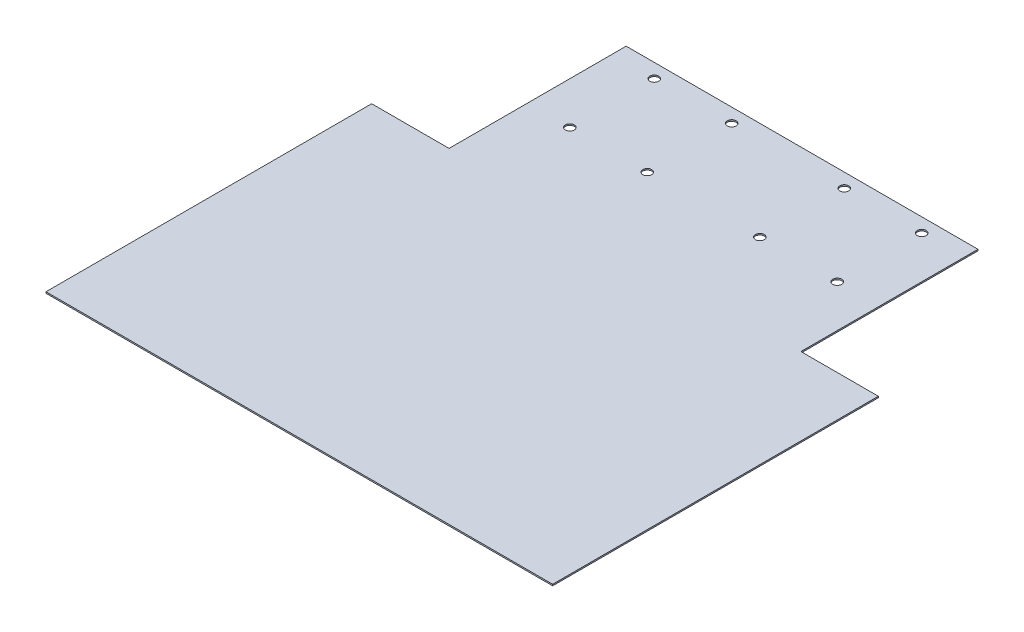
from build123d import *

# Parameters (mm, degrees)
SALIENTE_EXTRUIR1_DEPTH = 0.5
CORTAR_EXTRUIR1_REACH   = 182
CROQUIS5_R              = 1.585
CORTAR_EXTRUIR3_DEPTH   = 0.5
CORTAR_EXTRUIR4_REACH   = 2.5
CROQUIS6_R              = 1.585
CORTAR_EXTRUIR5_REACH   = 2.5
CROQUIS7_R              = 1.585
CROQUIS8_R              = 1.585
CORTAR_EXTRUIR6_DEPTH   = 0.5


with BuildPart() as part:
    # Croquis2 → Saliente-Extruir1 (new body)
    with BuildSketch(Plane(origin=(0, 0, 0), x_dir=(1, 0, 0), z_dir=(0, 1, 0))):
        Polygon((-90, 26.39), (-62.5, 26.39), (-62.5, 89.31), (62.5, 89.31), (62.5, 26.39), (90, 26.39), (90, -89.31), (-90, -89.31), align=None)
    saliente_extruir1 = extrude(amount=SALIENTE_EXTRUIR1_DEPTH)

    # Croquis3 → Cortar-Extruir1 (cut, up to next)
    with BuildSketch(Plane(origin=(90, 0, 0), x_dir=(0, 0, -1), z_dir=(1, 0, 0)), mode=Mode.PRIVATE) as cortar_extruir1_sk1:
        Polygon((-89.31, 0), (-87.93626129, 0.5), (-89.31, 0.5), align=None)
    cortar_extruir1_tool1 = extrude(cortar_extruir1_sk1.sketch, amount=-CORTAR_EXTRUIR1_REACH, mode=Mode.PRIVATE) & part.part
    add(cortar_extruir1_tool1.solids().sort_by_distance((90, 0.333333, 88.852087))[0], mode=Mode.SUBTRACT)

    # Croquis5 → Cortar-Extruir3 (cut)
    with BuildSketch(Plane(origin=(0, 0.5, 0), x_dir=(1, 0, 0), z_dir=(0, 1, 0))):
        with Locations((74, -24.974980583)):
            Circle(CROQUIS5_R)
    cortar_extruir3 = extrude(amount=-CORTAR_EXTRUIR3_DEPTH, mode=Mode.SUBTRACT)

    # Simetría1: Cortar-Extruir3 across plane
    add(cortar_extruir3.mirror(Plane(origin=(0, 0, 0), x_dir=(0, 0, 1), z_dir=(1, 0, 0))), mode=Mode.SUBTRACT)

    # Croquis6 → Cortar-Extruir4 (cut, up to next)
    with BuildSketch(Plane(origin=(0, 0.5, 0), x_dir=(1, 0, 0), z_dir=(0, 1, 0)), mode=Mode.PRIVATE) as cortar_extruir4_sk1:
        with Locations((-56.5, 35.81)):
            Circle(CROQUIS6_R)
    cortar_extruir4_tool1 = extrude(cortar_extruir4_sk1.sketch, amount=-CORTAR_EXTRUIR4_REACH, mode=Mode.PRIVATE) & part.part
    add(cortar_extruir4_tool1.solids().sort_by_distance((-56.5, 0.5, -35.81))[0], mode=Mode.SUBTRACT)
    # Croquis6 → Cortar-Extruir4 (cut, up to next)
    with BuildSketch(Plane(origin=(0, 0.5, 0), x_dir=(1, 0, 0), z_dir=(0, 1, 0)), mode=Mode.PRIVATE) as cortar_extruir4_sk2:
        with Locations((-15.5, 35.81)):
            Circle(CROQUIS6_R)
    cortar_extruir4_tool2 = extrude(cortar_extruir4_sk2.sketch, amount=-CORTAR_EXTRUIR4_REACH, mode=Mode.PRIVATE) & part.part
    add(cortar_extruir4_tool2.solids().sort_by_distance((-15.5, 0.5, -35.81))[0], mode=Mode.SUBTRACT)
    # Croquis6 → Cortar-Extruir4 (cut, up to next)
    with BuildSketch(Plane(origin=(0, 0.5, 0), x_dir=(1, 0, 0), z_dir=(0, 1, 0)), mode=Mode.PRIVATE) as cortar_extruir4_sk3:
        with Locations((-15.5, 84.31)):
            Circle(CROQUIS6_R)
    cortar_extruir4_tool3 = extrude(cortar_extruir4_sk3.sketch, amount=-CORTAR_EXTRUIR4_REACH, mode=Mode.PRIVATE) & part.part
    add(cortar_extruir4_tool3.solids().sort_by_distance((-15.5, 0.5, -84.31))[0], mode=Mode.SUBTRACT)
    # Croquis6 → Cortar-Extruir4 (cut, up to next)
    with BuildSketch(Plane(origin=(0, 0.5, 0), x_dir=(1, 0, 0), z_dir=(0, 1, 0)), mode=Mode.PRIVATE) as cortar_extruir4_sk4:
        with Locations((-56.5, 84.31)):
            Circle(CROQUIS6_R)
    cortar_extruir4_tool4 = extrude(cortar_extruir4_sk4.sketch, amount=-CORTAR_EXTRUIR4_REACH, mode=Mode.PRIVATE) & part.part
    add(cortar_extruir4_tool4.solids().sort_by_distance((-56.5, 0.5, -84.31))[0], mode=Mode.SUBTRACT)

    # Croquis7 → Cortar-Extruir5 (cut, up to next)
    with BuildSketch(Plane(origin=(0, 0.5, 0), x_dir=(1, 0, 0), z_dir=(0, 1, 0)), mode=Mode.PRIVATE) as cortar_extruir5_sk1:
        with Locations((56.5, 35.81)):
            Circle(CROQUIS7_R)
    cortar_extruir5_tool1 = extrude(cortar_extruir5_sk1.sketch, amount=-CORTAR_EXTRUIR5_REACH, mode=Mode.PRIVATE) & part.part
    add(cortar_extruir5_tool1.solids().sort_by_distance((56.5, 0.5, -35.81))[0], mode=Mode.SUBTRACT)
    # Croquis7 → Cortar-Extruir5 (cut, up to next)
    with BuildSketch(Plane(origin=(0, 0.5, 0), x_dir=(1, 0, 0), z_dir=(0, 1, 0)), mode=Mode.PRIVATE) as cortar_extruir5_sk2:
        with Locations((15.5, 35.81)):
            Circle(CROQUIS7_R)
    cortar_extruir5_tool2 = extrude(cortar_extruir5_sk2.sketch, amount=-CORTAR_EXTRUIR5_REACH, mode=Mode.PRIVATE) & part.part
    add(cortar_extruir5_tool2.solids().sort_by_distance((15.5, 0.5, -35.81))[0], mode=Mode.SUBTRACT)
    # Croquis7 → Cortar-Extruir5 (cut, up to next)
    with BuildSketch(Plane(origin=(0, 0.5, 0), x_dir=(1, 0, 0), z_dir=(0, 1, 0)), mode=Mode.PRIVATE) as cortar_extruir5_sk3:
        with Locations((15.5, 84.31)):
            Circle(CROQUIS7_R)
    cortar_extruir5_tool3 = extrude(cortar_extruir5_sk3.sketch, amount=-CORTAR_EXTRUIR5_REACH, mode=Mode.PRIVATE) & part.part
    add(cortar_extruir5_tool3.solids().sort_by_distance((15.5, 0.5, -84.31))[0], mode=Mode.SUBTRACT)
    # Croquis7 → Cortar-Extruir5 (cut, up to next)
    with BuildSketch(Plane(origin=(0, 0.5, 0), x_dir=(1, 0, 0), z_dir=(0, 1, 0)), mode=Mode.PRIVATE) as cortar_extruir5_sk4:
        with Locations((56.5, 84.31)):
            Circle(CROQUIS7_R)
    cortar_extruir5_tool4 = extrude(cortar_extruir5_sk4.sketch, amount=-CORTAR_EXTRUIR5_REACH, mode=Mode.PRIVATE) & part.part
    add(cortar_extruir5_tool4.solids().sort_by_distance((56.5, 0.5, -84.31))[0], mode=Mode.SUBTRACT)

    # Simetría3: Saliente-Extruir1 across plane
    add(saliente_extruir1.mirror(Plane(origin=(0, 0, 0), x_dir=(0, 0, 1), z_dir=(1, 0, 0))))

    # Croquis8 → Cortar-Extruir6 (cut)
    with BuildSketch(Plane(origin=(0, 0.5, 0), x_dir=(1, 0, 0), z_dir=(0, 1, 0))):
        with Locations((-20, 54.31)):
            Circle(CROQUIS8_R)
        with Locations((-47.5, 54.31)):
            Circle(CROQUIS8_R)
        with Locations((-47.5, 84.31)):
            Circle(CROQUIS8_R)
        with Locations((-20, 84.31)):
            Circle(CROQUIS8_R)
    cortar_extruir6 = extrude(amount=-CORTAR_EXTRUIR6_DEPTH, mode=Mode.SUBTRACT)

    # Simetría4: Cortar-Extruir6 across plane
    add(cortar_extruir6.mirror(Plane(origin=(0, 0, 0), x_dir=(0, 0, 1), z_dir=(1, 0, 0))), mode=Mode.SUBTRACT)


solid = part.part
